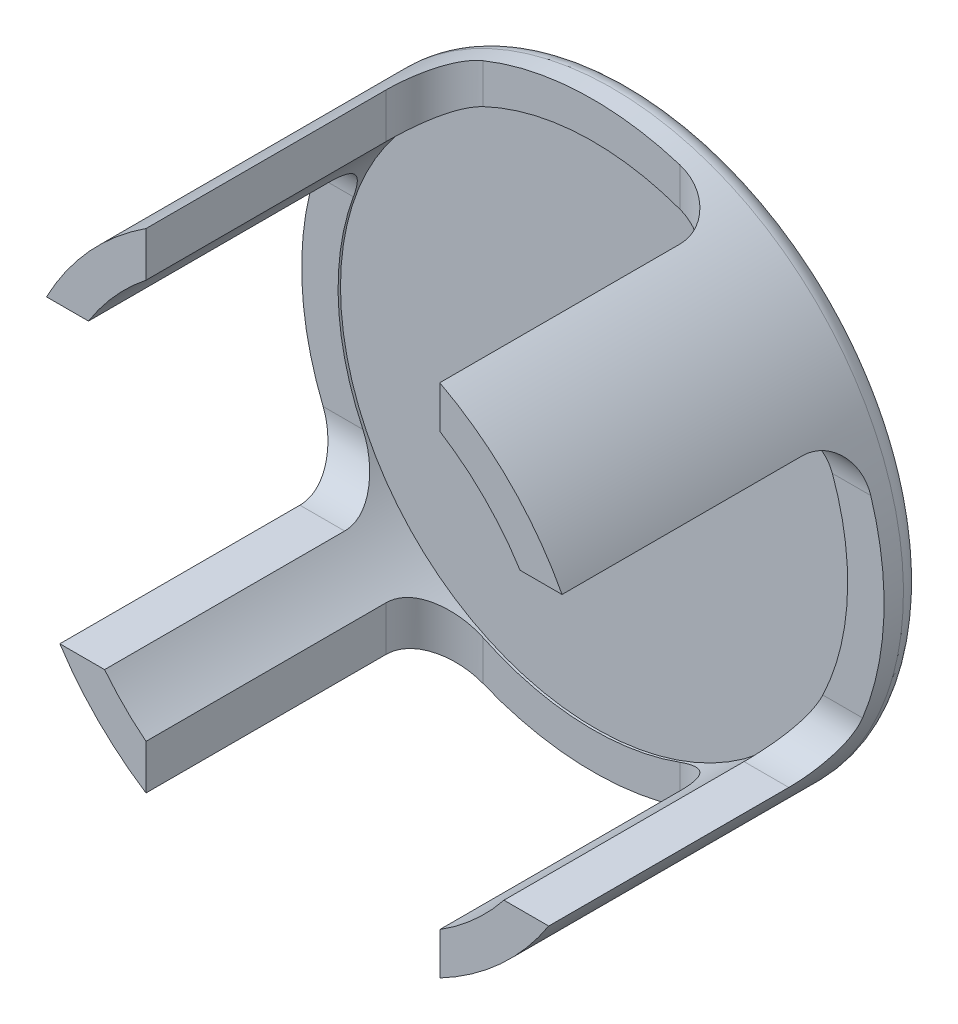
from build123d import *

# Parameters (mm, degrees)
SKETCH2_R                = 6
BOSS_EXTRUDE1_DEPTH      = 1
BOSS_EXTRUDE1_DEPTH_BACK = 5.746
SHELL1_T                 = -0.75
SKETCH3_W                = 5.946271115
SKETCH3_H                = 6.052851553
CUT_EXTRUDE1_DEPTH       = 40.659561396
FILLET1_R                = 1
CIRPATTERN1_COUNT        = 2
CIRPATTERN1_ANGLE        = 90
FILLET1_OF_CIRPATTERN1_R = 1
FILLET2_R                = 0.4


with BuildPart() as part:
    # Sketch2 → Boss-Extrude1 (new, two sides)
    with BuildSketch(Plane(origin=(0, 0, 4.668), x_dir=(-1, 0, 0), z_dir=(0, 0, -1))) as boss_extrude1_sk:
        with Locations((-0.092980153, 31.779690403)):
            Circle(SKETCH2_R)
    extrude(amount=BOSS_EXTRUDE1_DEPTH)
    extrude(boss_extrude1_sk.sketch, amount=-BOSS_EXTRUDE1_DEPTH_BACK)

    # Shell1
    shell1_openings = [part.faces().sort_by_distance(p)[0] for p in [
        (0.092980153, 31.779690403, 10.414),
    ]]
    offset(amount=SHELL1_T, openings=shell1_openings, kind=Kind.INTERSECTION)

    # Sketch3 → Cut-Extrude1 (cut, symmetric)
    with BuildSketch(Plane(origin=(0, 0, 0), x_dir=(0, 0, -1), z_dir=(1, 0, 0))):
        with Locations((-7.440864443, 31.545021025)):
            Rectangle(SKETCH3_W, SKETCH3_H)
    cut_extrude1 = extrude(amount=CUT_EXTRUDE1_DEPTH, both=True, mode=Mode.SUBTRACT)

    # Fillet1
    fillet1_edges = [part.edges().sort_by_distance(p)[0] for p in [
        (4.97154522, 34.571446801, 4.467728885),
        (-4.785584914, 34.571446801, 4.467728885),
        (4.668344707, 28.518595248, 4.467728885),
        (-4.482384401, 28.518595248, 4.467728885),
    ]]
    fillet(fillet1_edges, radius=FILLET1_R)

    # CirPattern1: Cut-Extrude1 ×2 about axis
    cirpattern1_axis = Axis((0.092980153, 31.779690403, 10.414), (0, 0, -1))
    for i in range(1, CIRPATTERN1_COUNT):
        add(cut_extrude1.rotate(cirpattern1_axis, i * CIRPATTERN1_ANGLE / (CIRPATTERN1_COUNT - 1)), mode=Mode.SUBTRACT)

    # Fillet1 of CirPattern1
    fillet1_of_cirpattern1_edges = [part.edges().sort_by_distance(p)[0] for p in [
        (2.884736551, 26.901125336, 4.467728885),
        (2.884736551, 36.65825547, 4.467728885),
        (-3.168115002, 27.204325849, 4.467728885),
        (-3.168115002, 36.355054957, 4.467728885),
    ]]
    fillet(fillet1_of_cirpattern1_edges, radius=FILLET1_OF_CIRPATTERN1_R)

    # Fillet2
    fillet2_edges = [part.edges().sort_by_distance(p)[0] for p in [
        (6.092980153, 31.779690403, 3.668),
    ]]
    fillet(fillet2_edges, radius=FILLET2_R)


solid = part.part
